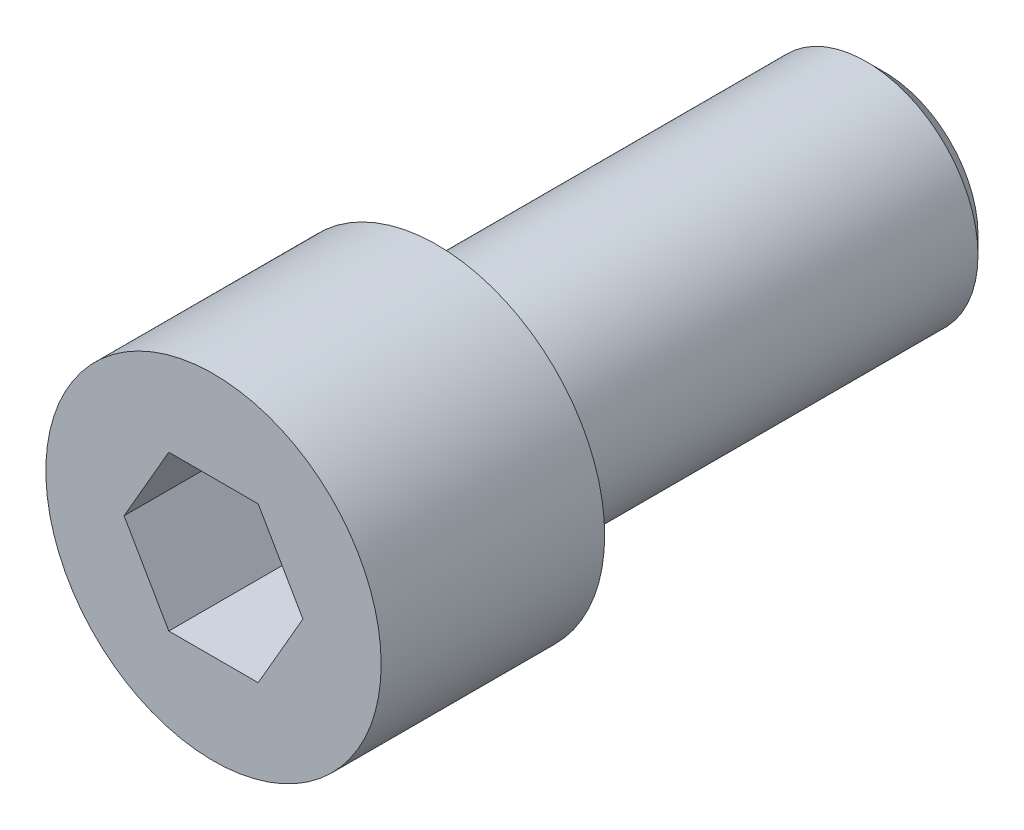
from build123d import *

# Parameters (mm, degrees)
SKETCH1_W          = 1.875
SKETCH1_H          = 2.5
SKETCH1_W_2        = 1.25
SKETCH1_H_2        = 5
CUT_EXTRUDE1_DEPTH = 1.5
FILLET1_R          = 0.15
CHAMFER1_SIZE      = 0.2


with BuildPart() as part:
    # Sketch1 → Revolve1 (revolve)
    with BuildSketch(Plane(origin=(0, 0, 0), x_dir=(1, 0, 0), z_dir=(0, 1, 0))):
        with Locations((0.9375, 1.25)):
            Rectangle(SKETCH1_W, SKETCH1_H)
        with Locations((0.625, 5)):
            Rectangle(SKETCH1_W_2, SKETCH1_H_2)
    revolve(axis=Axis((0, 0, -2.5), (0, 0, -1)))

    # Sketch2 → Cut-Extrude1 (cut)
    with BuildSketch(Plane.XY):
        Polygon((1, 0), (0.5, 0.866025404), (-0.5, 0.866025404), (-1, 0), (-0.5, -0.866025404), (0.5, -0.866025404), align=None)
    extrude(amount=-CUT_EXTRUDE1_DEPTH, mode=Mode.SUBTRACT)

    # Fillet1
    fillet1_edges = [part.edges().sort_by_distance(p)[0] for p in [
        (-1.25, 0, -2.5),
    ]]
    fillet(fillet1_edges, radius=FILLET1_R)

    # Chamfer1
    chamfer1_edges = [part.edges().sort_by_distance(p)[0] for p in [
        (-1.25, 0, -7.5),
    ]]
    chamfer(chamfer1_edges, length=CHAMFER1_SIZE)


solid = part.part
